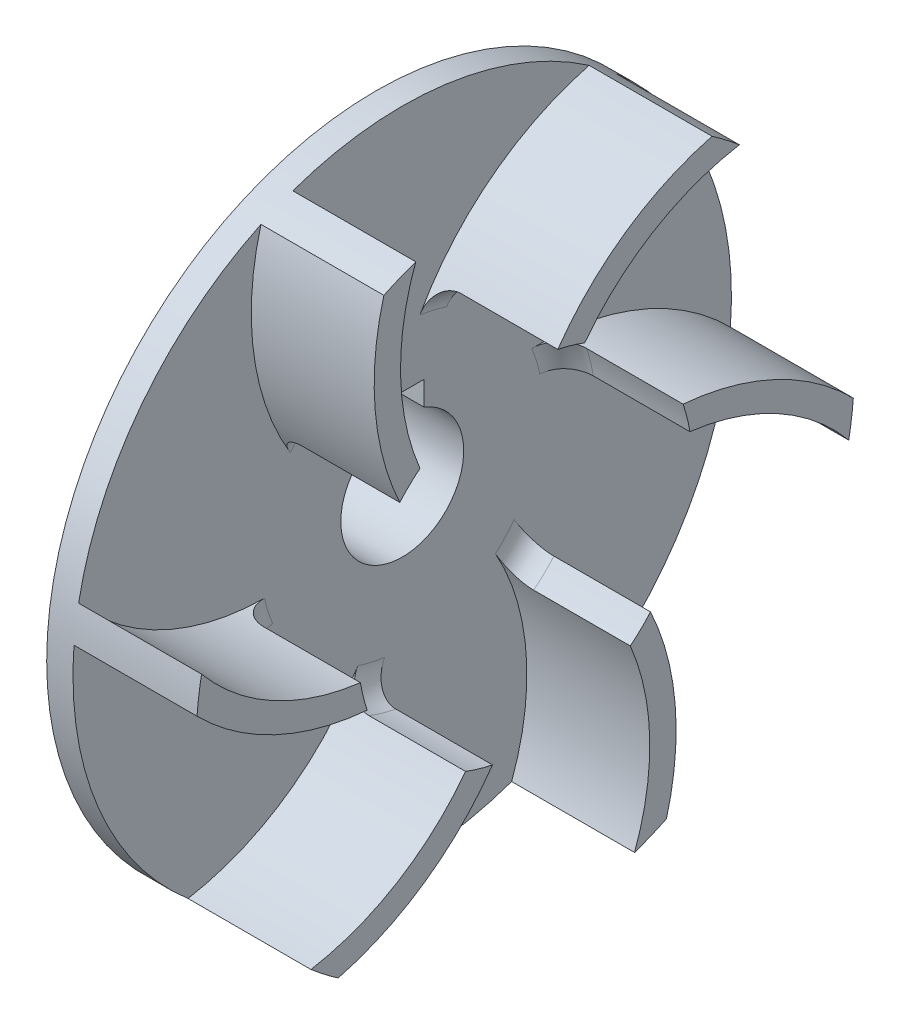
from build123d import *
from build123d.topology import SkipClean

# Parameters (mm, degrees)
FILLET1_R                = 6
CUT_EXTRUDE1_DEPTH       = 20
BOSS_EXTRUDE1_DEPTH      = 14
FILLET2_R                = 3
CIRPATTERN1_COUNT        = 6
FILLET2_OF_CIRPATTERN1_R = 3


with BuildPart() as part:
    # Sketch1 → Revolve1 (revolve)
    with BuildSketch(Plane.XY, mode=Mode.PRIVATE) as revolve1_sk:
        Polygon((0, 7), (0, 12.5), (16, 12.5), (16, 37.5), (19, 37.5), (19, 7), align=None)
    revolve(revolve1_sk.sketch.rotate(Axis((-91.900691054, 0, 0), (1, 0, 0)), 90), axis=Axis((-91.900691054, 0, 0), (1, 0, 0)))  # turned: the seam where the file's is

    # Fillet1
    fillet1_edges = [part.edges().sort_by_distance(p)[0] for p in [
        (16, 0, -12.5),
    ]]
    fillet(fillet1_edges, radius=FILLET1_R)

    # Sketch2 → Cut-Extrude1 (cut, through all)
    with BuildSketch(Plane(origin=(19, 0, 0), x_dir=(0, 0, -1), z_dir=(1, 0, 0))):
        with BuildLine():
            Line((-2.5, 6.538348415), (-2.5, 9.3))
            Line((-2.5, 9.3), (2.5, 9.3))
            Line((2.5, 9.3), (2.5, 6.538348415))
            ThreePointArc((2.5, 6.538348415), (0, -7), (-2.5, 6.538348415))
        make_face()
    extrude(amount=-CUT_EXTRUDE1_DEPTH, mode=Mode.SUBTRACT)

    # Sketch3 → Boss-Extrude1 (add)
    with BuildSketch(Plane(origin=(19, 0, 0), x_dir=(0, 0, -1), z_dir=(1, 0, 0))):
        with BuildLine():
            ThreePointArc((-36.861475704, 6.890690018), (-28.755483578, 0.217996332), (-18.761663039, -3))
            ThreePointArc((-18.761663039, -3), (-18.443627284, -4.564275696), (-17.995407864, -6.09633462))
            ThreePointArc((-17.995407864, -6.09633462), (-28.49792429, -3.274961963), (-37.379807383, 3))
            ThreePointArc((-37.379807383, 3), (-37.171580486, 4.952131277), (-36.861475704, 6.890690018))
        make_face()
    boss_extrude1 = extrude(amount=BOSS_EXTRUDE1_DEPTH)

    # Fillet2
    fillet2_edges = [part.edges().sort_by_distance(p)[0] for p in [
        (19, -4.564275696, 18.443627284),
    ]]
    fillet(fillet2_edges, radius=FILLET2_R)

    # CirPattern1: Boss-Extrude1 ×6 about axis
    with SkipClean():  # keep this step's faces unmerged: merging them makes the solid invalid here
        cirpattern1_axis = Axis((0, 0, 0), (1, 0, 0))
        for i in range(1, CIRPATTERN1_COUNT):
            add(boss_extrude1.rotate(cirpattern1_axis, i * 360 / CIRPATTERN1_COUNT))

    # Fillet2 of CirPattern1
    fillet2_of_cirpattern1_edges = [part.edges().sort_by_distance(p)[0] for p in [
        (19, -18.254787613, 5.269034939),
        (19, -13.690511918, -13.174592344),
        (19, 4.564275696, -18.443627284),
        (19, 18.254787613, -5.269034939),
        (19, 13.690511918, 13.174592344),
    ]]
    fillet(fillet2_of_cirpattern1_edges, radius=FILLET2_OF_CIRPATTERN1_R)


solid = part.part
